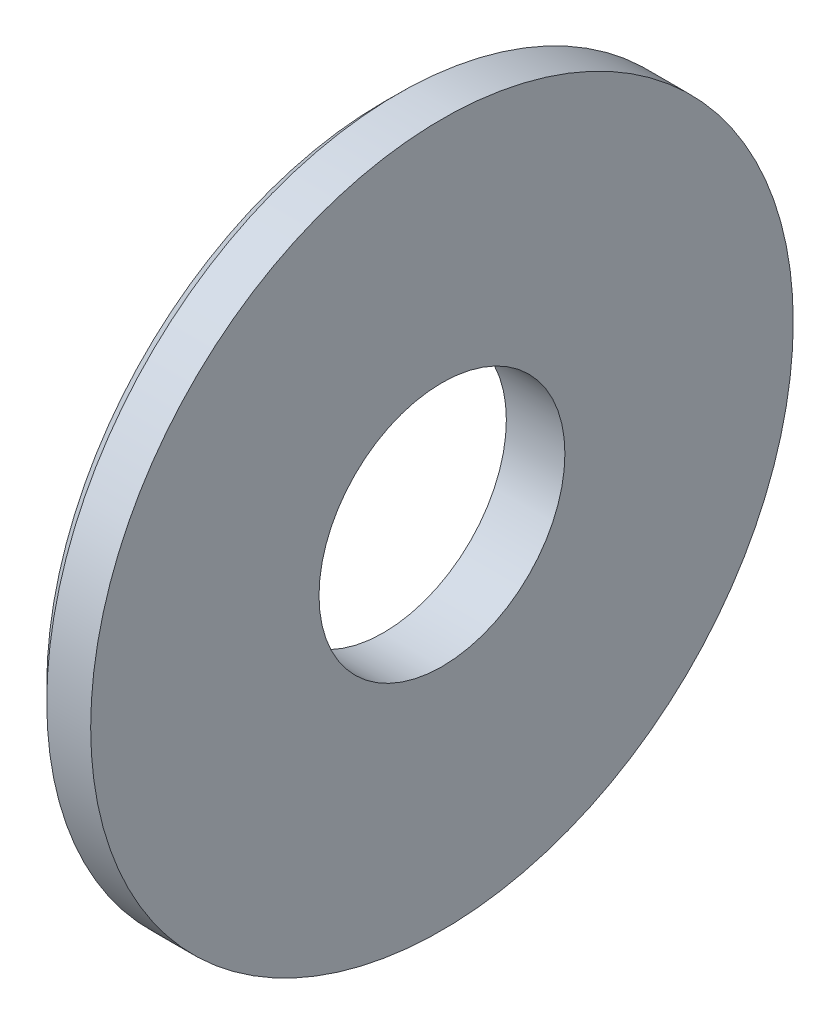
from build123d import *

# Parameters (mm, degrees)
CROQUIS1_W    = 2
CROQUIS1_H    = 7.8
CHAFL_N1_SIZE = 0.5


with BuildPart() as part:
    # Croquis1 → Revolución1 (revolve)
    with BuildSketch(Plane(origin=(0, 0, 0), x_dir=(-1, 0, 0), z_dir=(0, 0, -1))):
        with Locations((-1, 8.1)):
            Rectangle(CROQUIS1_W, CROQUIS1_H)
    revolve(axis=Axis((2, 0, 0), (-1, 0, 0)))

    # Chaflán1
    chafl_n1_edges = [part.edges().sort_by_distance(p)[0] for p in [
        (0, -12, 0),
    ]]
    chamfer(chafl_n1_edges, length=CHAFL_N1_SIZE)


solid = part.part
